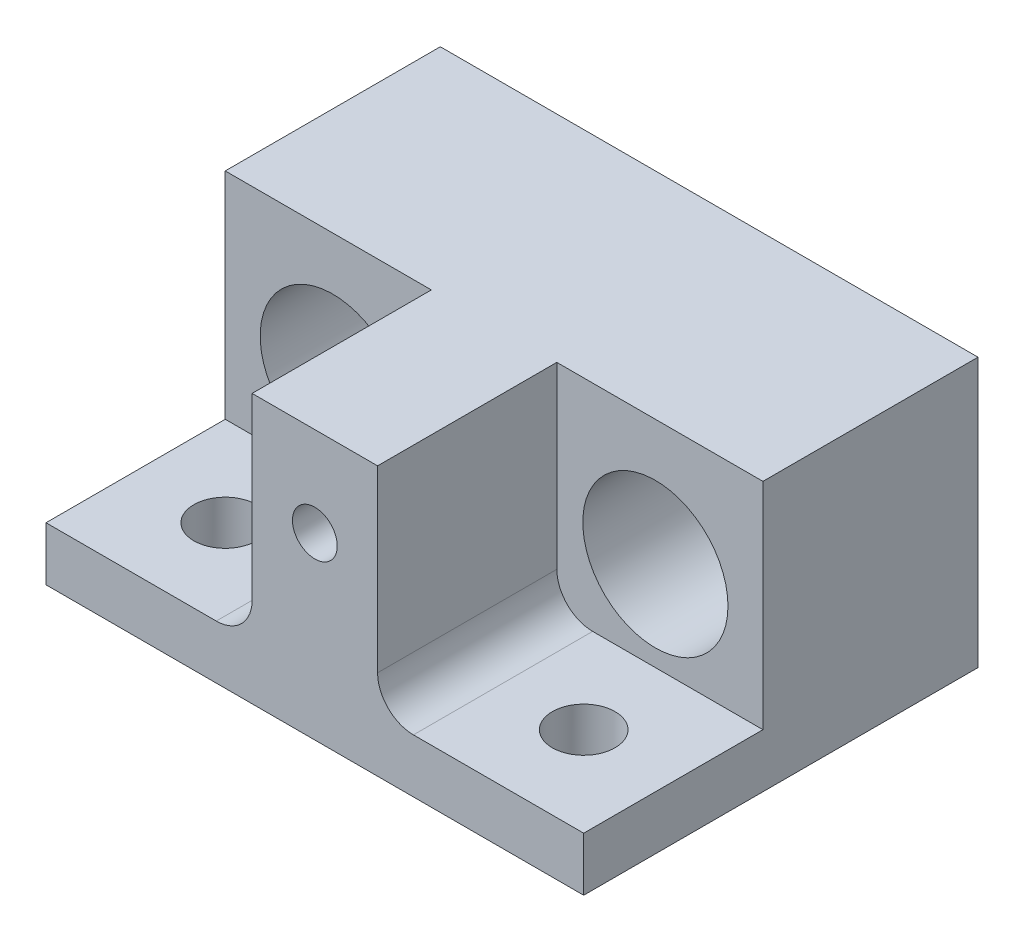
from build123d import *

# Parameters (mm, degrees)
ESQUISSE1_W             = 30
ESQUISSE1_H             = 22
BOSS_EXTRU_1_DEPTH      = 15
ESQUISSE2_W             = 11.5
ESQUISSE2_H             = 10
ENL_V_MAT_EXTRU_2_DEPTH = 12
CONG_1_R                = 2
ESQUISSE3_R             = 4.05
ENL_V_MAT_EXTRU_3_DEPTH = 13
ENL_V_MAT_EXTRU_4_REACH = 5
ESQUISSE4_R             = 1.75
TROU_TARAUD_M31_D       = 2.5
TROU_TARAUD_M31_DEPTH   = 10
TROU_TARAUD_M31_TIP     = 0.751075774


with BuildPart() as part:
    # Esquisse1 → Boss.-Extru.1 (new body)
    with BuildSketch(Plane(origin=(0, 0, 0), x_dir=(1, 0, 0), z_dir=(0, 1, 0))):
        Rectangle(ESQUISSE1_W, ESQUISSE1_H)
    extrude(amount=BOSS_EXTRU_1_DEPTH)

    # Esquisse2 → Enlèv. mat.-Extru.2 (cut)
    with BuildSketch(Plane(origin=(0, 15, 0), x_dir=(1, 0, 0), z_dir=(0, 1, 0))):
        with Locations((-9.25, -6)):
            Rectangle(ESQUISSE2_W, ESQUISSE2_H)
        with Locations((9.25, -6)):
            Rectangle(ESQUISSE2_W, ESQUISSE2_H)
    extrude(amount=-ENL_V_MAT_EXTRU_2_DEPTH, mode=Mode.SUBTRACT)

    # Congé1
    cong_1_edges = [part.edges().sort_by_distance(p)[0] for p in [
        (-3.5, 3, 6),
        (3.5, 3, 6),
    ]]
    fillet(cong_1_edges, radius=CONG_1_R)

    # Esquisse3 → Enlèv. mat.-Extru.3 (cut, through all)
    with BuildSketch(Plane.XY.offset(1)):
        with Locations((-9, 8)):
            Circle(ESQUISSE3_R)
        with Locations((9, 8)):
            Circle(ESQUISSE3_R)
    extrude(amount=-ENL_V_MAT_EXTRU_3_DEPTH, mode=Mode.SUBTRACT)

    # Esquisse4 → Enlèv. mat.-Extru.4 (cut, up to next)
    with BuildSketch(Plane(origin=(0, 3, 0), x_dir=(1, 0, 0), z_dir=(0, 1, 0)), mode=Mode.PRIVATE) as enl_v_mat_extru_4_sk1:
        with Locations(Location((-10, -6, 0), (0, 0, 270))):  # turned: the seam where the file's is
            Circle(ESQUISSE4_R)
    enl_v_mat_extru_4_tool1 = extrude(enl_v_mat_extru_4_sk1.sketch, amount=-ENL_V_MAT_EXTRU_4_REACH, mode=Mode.PRIVATE) & part.part
    add(enl_v_mat_extru_4_tool1.solids().sort_by_distance((-10, 3, 6))[0], mode=Mode.SUBTRACT)
    # Esquisse4 → Enlèv. mat.-Extru.4 (cut, up to next)
    with BuildSketch(Plane(origin=(0, 3, 0), x_dir=(1, 0, 0), z_dir=(0, 1, 0)), mode=Mode.PRIVATE) as enl_v_mat_extru_4_sk2:
        with Locations(Location((10, -6, 0), (0, 0, 270))):  # turned: the seam where the file's is
            Circle(ESQUISSE4_R)
    enl_v_mat_extru_4_tool2 = extrude(enl_v_mat_extru_4_sk2.sketch, amount=-ENL_V_MAT_EXTRU_4_REACH, mode=Mode.PRIVATE) & part.part
    add(enl_v_mat_extru_4_tool2.solids().sort_by_distance((10, 3, 6))[0], mode=Mode.SUBTRACT)

    # Trou taraudé M31
    with Locations(Plane.XY.offset(11)):
        with Locations((0, 10)):
            Hole(TROU_TARAUD_M31_D / 2, depth=TROU_TARAUD_M31_DEPTH)
            with Locations((0, 0, -(TROU_TARAUD_M31_DEPTH + TROU_TARAUD_M31_TIP / 2))):  # 118° drill point
                Cone(0, TROU_TARAUD_M31_D / 2, TROU_TARAUD_M31_TIP, mode=Mode.SUBTRACT)


solid = part.part
